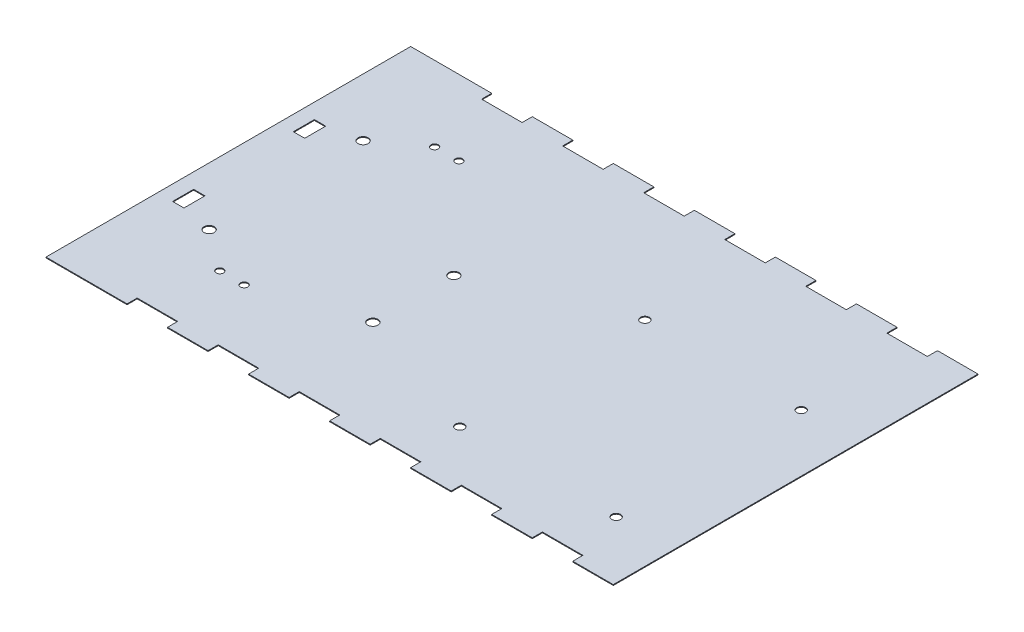
from build123d import *

# Parameters (mm, degrees)
SKETCH1_W           = 177.8
SKETCH1_H           = 114.3
BOSS_EXTRUDE1_DEPTH = 0.254
SKETCH2_R           = 1.143
SKETCH2_W           = 12.7
SKETCH2_H           = 3.175
CUT_EXTRUDE1_DEPTH  = 1.254
SKETCH3_R           = 1.375
SKETCH3_R_2         = 1.5875
SKETCH3_W           = 3.556
SKETCH3_H           = 6.604
CUT_EXTRUDE2_DEPTH  = 1.254


with BuildPart() as part:
    # Sketch1 → Boss-Extrude1 (new body)
    with BuildSketch(Plane(origin=(0, 0, 0), x_dir=(1, 0, 0), z_dir=(0, 1, 0))):
        Rectangle(SKETCH1_W, SKETCH1_H)
    extrude(amount=BOSS_EXTRUDE1_DEPTH)

    # Sketch2 → Cut-Extrude1 (cut, through all)
    with BuildSketch(Plane(origin=(0, 0.254, 0), x_dir=(1, 0, 0), z_dir=(0, 1, 0))):
        with Locations((-57.912, -33.655)):
            Circle(SKETCH2_R)
        with Locations((-50.292, -33.655)):
            Circle(SKETCH2_R)
        with Locations((-50.292, 33.655)):
            Circle(SKETCH2_R)
        with Locations((-57.912, 33.655)):
            Circle(SKETCH2_R)
        with Locations((69.85, -55.5625)):
            Rectangle(SKETCH2_W, SKETCH2_H)
        with Locations((44.45, -55.5625)):
            Rectangle(SKETCH2_W, SKETCH2_H)
        with Locations((19.05, -55.5625)):
            Rectangle(SKETCH2_W, SKETCH2_H)
        with Locations((-6.35, -55.5625)):
            Rectangle(SKETCH2_W, SKETCH2_H)
        with Locations((-31.75, -55.5625)):
            Rectangle(SKETCH2_W, SKETCH2_H)
        with Locations((-57.15, -55.5625)):
            Rectangle(SKETCH2_W, SKETCH2_H)
        with Locations((69.85, 55.5625)):
            Rectangle(SKETCH2_W, SKETCH2_H)
        with Locations((44.45, 55.5625)):
            Rectangle(SKETCH2_W, SKETCH2_H)
        with Locations((19.05, 55.5625)):
            Rectangle(SKETCH2_W, SKETCH2_H)
        with Locations((-6.35, 55.5625)):
            Rectangle(SKETCH2_W, SKETCH2_H)
        with Locations((-31.75, 55.5625)):
            Rectangle(SKETCH2_W, SKETCH2_H)
        with Locations((-57.15, 55.5625)):
            Rectangle(SKETCH2_W, SKETCH2_H)
    extrude(amount=-CUT_EXTRUDE1_DEPTH, mode=Mode.SUBTRACT)

    # Sketch3 → Cut-Extrude2 (cut, through all)
    with BuildSketch(Plane(origin=(0, 0.254, 0), x_dir=(1, 0, 0), z_dir=(0, 1, 0))):
        with Locations((70.976500958, -38.327807122)):
            Circle(SKETCH3_R)
        with Locations((21.976500958, -38.327807122)):
            Circle(SKETCH3_R)
        with Locations((21.976500958, 19.672192878)):
            Circle(SKETCH3_R)
        with Locations((70.976500958, 19.672192878)):
            Circle(SKETCH3_R)
        with Locations((-70.786531145, -24.13)):
            Circle(SKETCH3_R_2)
        with Locations((-70.786531145, 24.13)):
            Circle(SKETCH3_R_2)
        with Locations((-19.989071209, -23.622)):
            Circle(SKETCH3_R_2)
        with Locations((-19.989071209, 1.778)):
            Circle(SKETCH3_R_2)
        with Locations((-82.380316409, 18.923)):
            Rectangle(SKETCH3_W, SKETCH3_H)
        with Locations((-82.380316409, -18.923)):
            Rectangle(SKETCH3_W, SKETCH3_H)
    extrude(amount=-CUT_EXTRUDE2_DEPTH, mode=Mode.SUBTRACT)


solid = part.part
